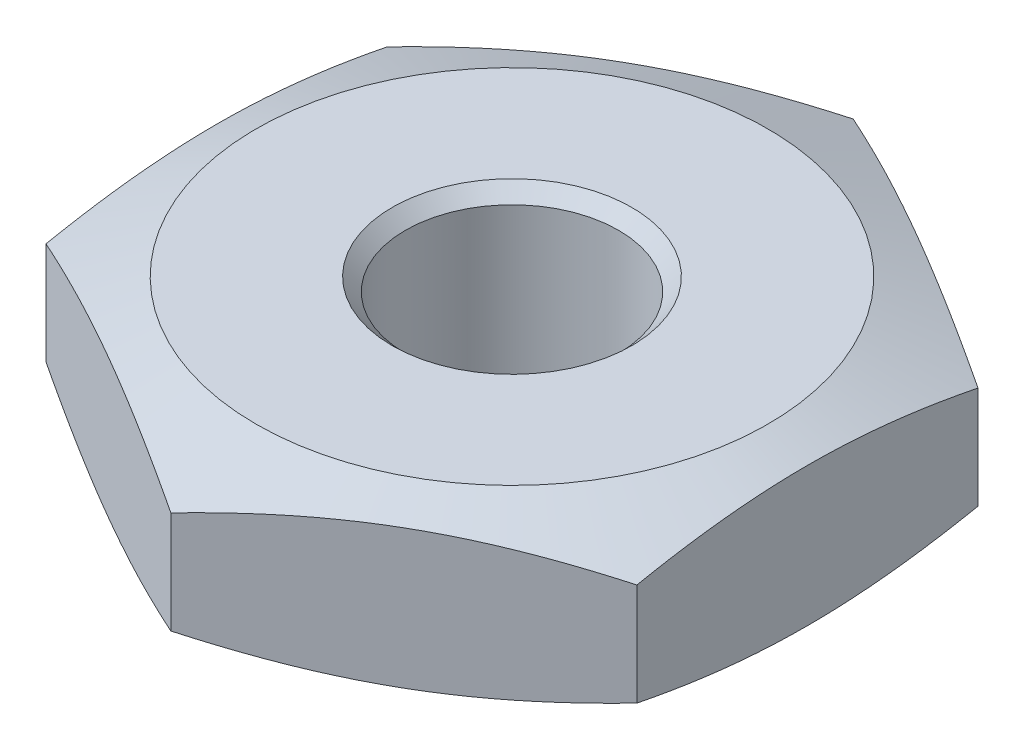
from build123d import *

# Parameters (mm, degrees)
EXTRUDE_1_DEPTH       = 10
M14X1_5_1_D           = 12.5
M14X1_5_1_CSINK_D     = 14.05
M14X1_5_1_CSINK_ANGLE = 90


with BuildPart() as part:
    # 草图1 → 凸台-拉伸1 (new body)
    with BuildSketch(Plane(origin=(0, 0, 0), x_dir=(1, 0, 0), z_dir=(0, 1, 0))):
        Polygon((0, -20), (17.320508076, -10), (17.320508076, 10), (0, 20), (-17.320508076, 10), (-17.320508076, -10), align=None)
    extrude(amount=EXTRUDE_1_DEPTH)

    # M14x1.5 螺纹孔1 (through all)
    with Locations(Plane(origin=(0, 10, 0), x_dir=(1, 0, 0), z_dir=(0, 1, 0))):
        with Locations((0, 0)):
            CounterSinkHole(M14X1_5_1_D / 2, M14X1_5_1_CSINK_D / 2, counter_sink_angle=M14X1_5_1_CSINK_ANGLE)

    # 草图7 → 切除-旋转1 (revolve, cut)
    with BuildSketch(Plane(origin=(0, 0, 0), x_dir=(0, 0, -1), z_dir=(1, 0, 0))):
        Polygon((20, 10), (20, 8), (15, 10), align=None)
        Polygon((20, 2), (15, 0), (20, 0), align=None)
    revolve(axis=Axis((0, 15.71595543, 0), (0, -1, 0)), mode=Mode.SUBTRACT)


solid = part.part
